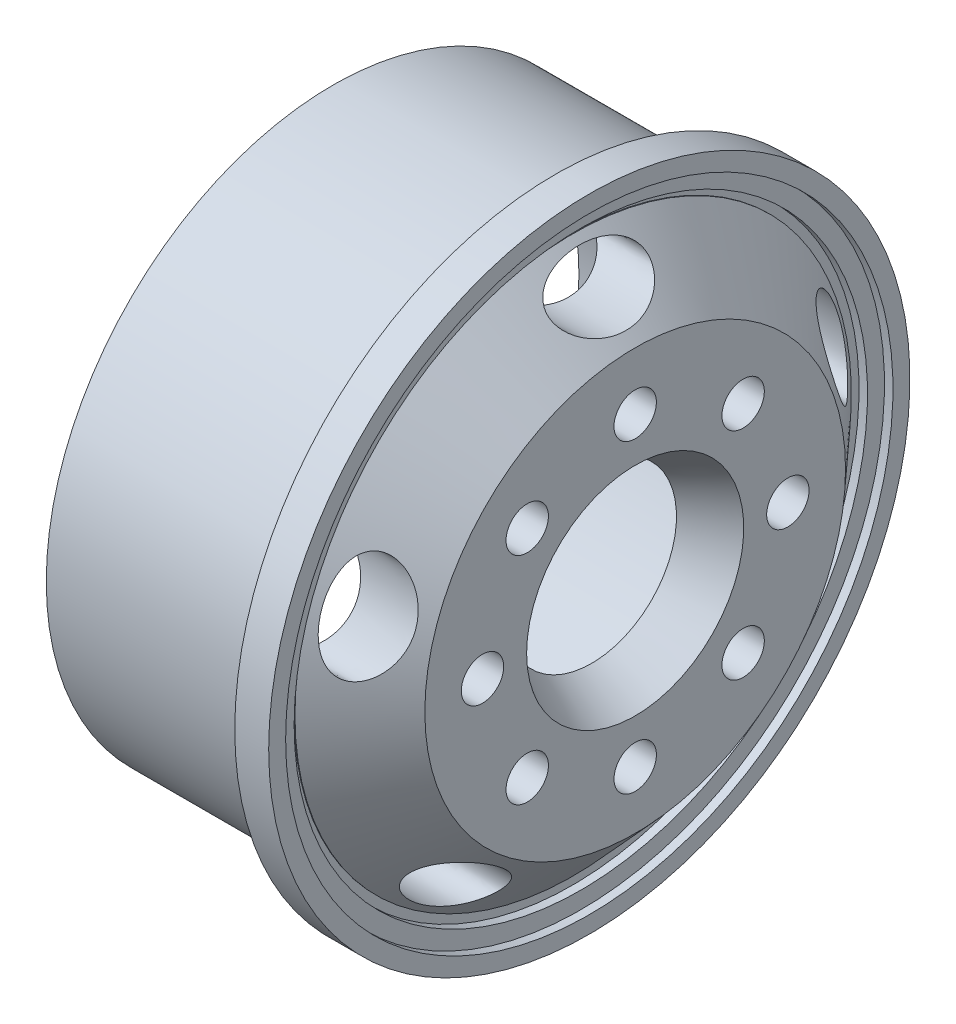
from build123d import *

# Parameters (mm, degrees)
SKETCH2_R          = 1.25
CUT_EXTRUDE1_DEPTH = 33.121596447
CUT_EXTRUDE3_REACH = 34.122
SKETCH4_RX         = 3
SKETCH4_RY         = 1.5


with BuildPart() as part:
    # Sketch1 → Revolve1 (revolve)
    with BuildSketch(Plane(origin=(0, 0, 0), x_dir=(1, 0, 0), z_dir=(0, 1, 0)), mode=Mode.PRIVATE) as revolve1_sk:
        Polygon((4.796305636, 16.9), (4.796305636, 18.9), (6.296305636, 18.9), (6.796305636, 18.9), (6.796305636, 17.9), (6.296305636, 17.9), (6.296305636, 16.9), (5.796305636, 16.9), (5.796305636, 16.4), (5.845774038, 16.4), (9.501382349, 12.4), (9.501382349, 6.4), (6.936305636, 5), (6.936305636, 11.490924884), (4.186305636, 14.5), (-8.313694364, 14.5), (-8.313694364, 16.9), align=None)
    revolve(revolve1_sk.sketch.rotate(Axis((-37.278866169, 0, 0), (1, 0, 0)), 180), axis=Axis((-37.278866169, 0, 0), (1, 0, 0)))

    # Sketch2 → Cut-Extrude1 (cut, through all)
    with BuildSketch(Plane(origin=(9.501382349, 0, 0), x_dir=(0, 0, -1), z_dir=(1, 0, 0))):
        with Locations((0, 9)):
            Circle(SKETCH2_R)
        with Locations((6.363961031, 6.363961031)):
            Circle(SKETCH2_R)
        with Locations((9, 0)):
            Circle(SKETCH2_R)
        with Locations((6.363961031, -6.363961031)):
            Circle(SKETCH2_R)
        with Locations((0, -9)):
            Circle(SKETCH2_R)
        with Locations((-6.363961031, -6.363961031)):
            Circle(SKETCH2_R)
        with Locations((-9, 0)):
            Circle(SKETCH2_R)
        with Locations((-6.363961031, 6.363961031)):
            Circle(SKETCH2_R)
    extrude(amount=-CUT_EXTRUDE1_DEPTH, mode=Mode.SUBTRACT)

    # Cut-Extrude3: up to this cone (the profile starts outside it)
    cut_extrude3_end = Plane(origin=(9.501382, 0, 0), z_dir=(-1, 0, 0)).offset(-7.936502761) * Cone(1.094e-06, 56.070228875, 51.242697661, align=(Align.CENTER, Align.CENTER, Align.MIN), mode=Mode.PRIVATE)
    # Sketch4 → Cut-Extrude3 (cut, up to the surface)
    with BuildSketch(Plane(origin=(9.501382349, 0, 0), x_dir=(0, 0, -1), z_dir=(1, 0, 0)), mode=Mode.PRIVATE) as cut_extrude3_sk1:
        with Locations((0, 14.5)):
            Ellipse(SKETCH4_RX, SKETCH4_RY)
    cut_extrude3_tool1 = extrude(cut_extrude3_sk1.sketch, amount=-CUT_EXTRUDE3_REACH, mode=Mode.PRIVATE) - cut_extrude3_end
    add(cut_extrude3_tool1.solids().sort_by_distance((9.501382, 14.5, 0))[0], mode=Mode.SUBTRACT)
    # Sketch4 → Cut-Extrude3 (cut, up to the surface)
    with BuildSketch(Plane(origin=(9.501382349, 0, 0), x_dir=(0, 0, -1), z_dir=(1, 0, 0)), mode=Mode.PRIVATE) as cut_extrude3_sk2:
        with Locations(Location((13.790319486, 4.480746418), (0, 0, -72))):
            Ellipse(SKETCH4_RX, SKETCH4_RY)
    cut_extrude3_tool2 = extrude(cut_extrude3_sk2.sketch, amount=-CUT_EXTRUDE3_REACH, mode=Mode.PRIVATE) - cut_extrude3_end
    add(cut_extrude3_tool2.solids().sort_by_distance((9.501382, 4.480746, -13.790319))[0], mode=Mode.SUBTRACT)
    # Sketch4 → Cut-Extrude3 (cut, up to the surface)
    with BuildSketch(Plane(origin=(9.501382349, 0, 0), x_dir=(0, 0, -1), z_dir=(1, 0, 0)), mode=Mode.PRIVATE) as cut_extrude3_sk3:
        with Locations(Location((8.522886158, -11.730746418), (0, 0, -144))):
            Ellipse(SKETCH4_RX, SKETCH4_RY)
    cut_extrude3_tool3 = extrude(cut_extrude3_sk3.sketch, amount=-CUT_EXTRUDE3_REACH, mode=Mode.PRIVATE) - cut_extrude3_end
    add(cut_extrude3_tool3.solids().sort_by_distance((9.501382, -11.730746, -8.522886))[0], mode=Mode.SUBTRACT)
    # Sketch4 → Cut-Extrude3 (cut, up to the surface)
    with BuildSketch(Plane(origin=(9.501382349, 0, 0), x_dir=(0, 0, -1), z_dir=(1, 0, 0)), mode=Mode.PRIVATE) as cut_extrude3_sk4:
        with Locations(Location((-8.522886158, -11.730746418), (0, 0, 144))):
            Ellipse(SKETCH4_RX, SKETCH4_RY)
    cut_extrude3_tool4 = extrude(cut_extrude3_sk4.sketch, amount=-CUT_EXTRUDE3_REACH, mode=Mode.PRIVATE) - cut_extrude3_end
    add(cut_extrude3_tool4.solids().sort_by_distance((9.501382, -11.730746, 8.522886))[0], mode=Mode.SUBTRACT)
    # Sketch4 → Cut-Extrude3 (cut, up to the surface)
    with BuildSketch(Plane(origin=(9.501382349, 0, 0), x_dir=(0, 0, -1), z_dir=(1, 0, 0)), mode=Mode.PRIVATE) as cut_extrude3_sk5:
        with Locations(Location((-13.790319486, 4.480746418), (0, 0, -108))):
            Ellipse(SKETCH4_RX, SKETCH4_RY)
    cut_extrude3_tool5 = extrude(cut_extrude3_sk5.sketch, amount=-CUT_EXTRUDE3_REACH, mode=Mode.PRIVATE) - cut_extrude3_end
    add(cut_extrude3_tool5.solids().sort_by_distance((9.501382, 4.480746, 13.790319))[0], mode=Mode.SUBTRACT)


solid = part.part
